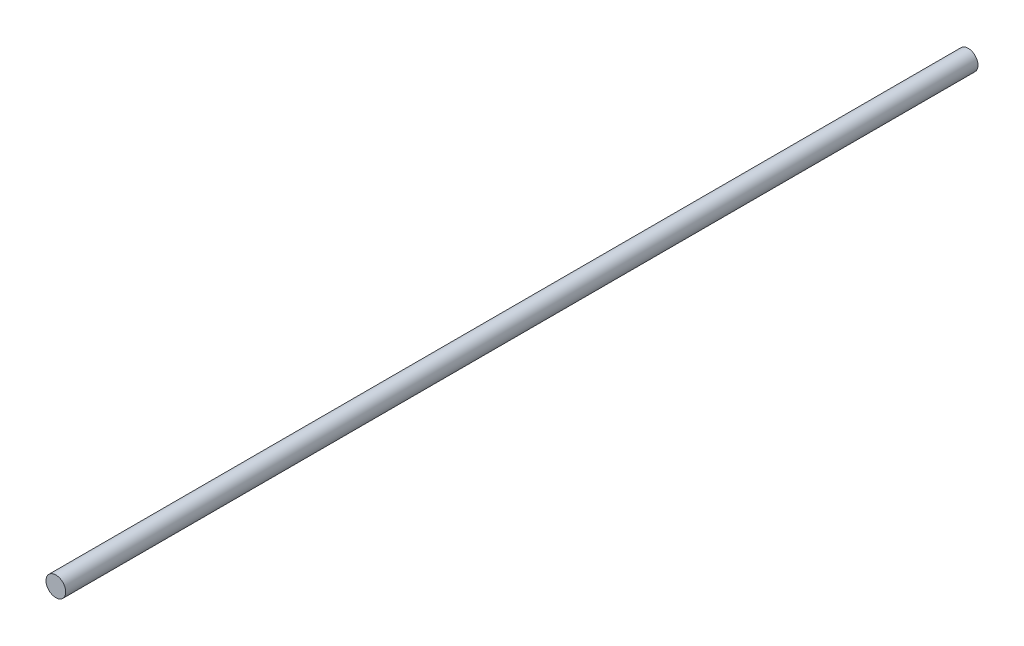
from build123d import *

# Parameters (mm, degrees)
ESBO_O1_R                = 4
RESSALTO_EXTRUS_O1_DEPTH = 370


with BuildPart() as part:
    # Esboço1 → Ressalto-extrusão1 (new body)
    with BuildSketch(Plane.XY):
        Circle(ESBO_O1_R)
    extrude(amount=RESSALTO_EXTRUS_O1_DEPTH)


solid = part.part
